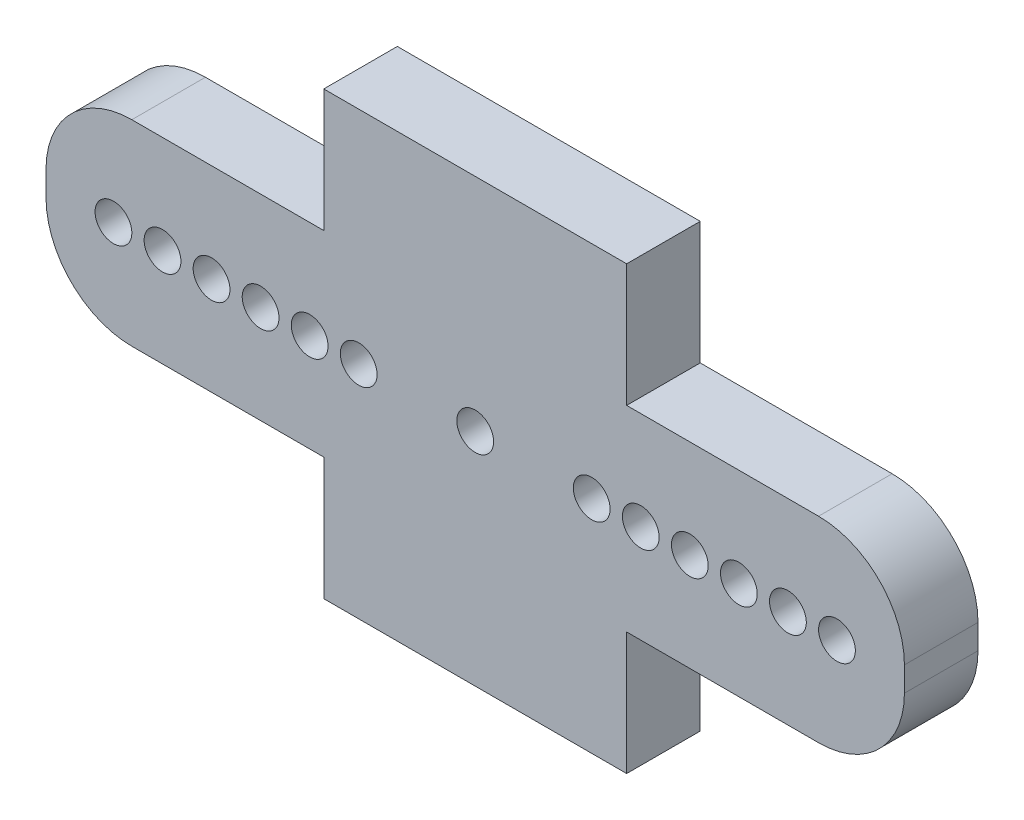
from build123d import *

# Parameters (mm, degrees)
SKETCH1_R           = 0.75
BOSS_EXTRUDE1_DEPTH = 1.5
SKETCH2_R           = 0.75
CUT_EXTRUDE1_DEPTH  = 4


with BuildPart() as part:
    # Sketch1 → Boss-Extrude1 (new body, symmetric)
    with BuildSketch(Plane.XY):
        with BuildLine():
            Line((-14, 4), (-6.175, 4))
            Line((-6.175, 4), (-6.175, 9))
            Line((-6.175, 9), (6.175, 9))
            Line((6.175, 9), (6.175, 4))
            Line((6.175, 4), (14, 4))
            ThreePointArc((14, 4), (16.474873734, 2.974873734), (17.5, 0.5))
            Line((17.5, 0.5), (17.5, -0.5))
            ThreePointArc((17.5, -0.5), (16.474873734, -2.974873734), (14, -4))
            Line((14, -4), (6.175, -4))
            Line((6.175, -4), (6.175, -9))
            Line((6.175, -9), (-6.175, -9))
            Line((-6.175, -9), (-6.175, -4))
            Line((-6.175, -4), (-14, -4))
            ThreePointArc((-14, -4), (-16.474873734, -2.974873734), (-17.5, -0.5))
            Line((-17.5, -0.5), (-17.5, 0.5))
            ThreePointArc((-17.5, 0.5), (-16.474873734, 2.974873734), (-14, 4))
        make_face()
        Circle(SKETCH1_R, mode=Mode.SUBTRACT)
    extrude(amount=BOSS_EXTRUDE1_DEPTH, both=True)

    # Sketch2 → Cut-Extrude1 (cut, through all)
    with BuildSketch(Plane.XY.offset(1.5)):
        with Locations((-14.75, 0)):
            Circle(SKETCH2_R)
        with Locations((-12.75, 0)):
            Circle(SKETCH2_R)
        with Locations((-10.75, 0)):
            Circle(SKETCH2_R)
        with Locations((-8.75, 0)):
            Circle(SKETCH2_R)
        with Locations((-6.75, 0)):
            Circle(SKETCH2_R)
        with Locations((-4.75, 0)):
            Circle(SKETCH2_R)
    cut_extrude1 = extrude(amount=-CUT_EXTRUDE1_DEPTH, mode=Mode.SUBTRACT)

    # Mirror1: Cut-Extrude1 across plane
    add(cut_extrude1.mirror(Plane(origin=(0, 0, 0), x_dir=(0, 0, 1), z_dir=(1, 0, 0))), mode=Mode.SUBTRACT)


solid = part.part
